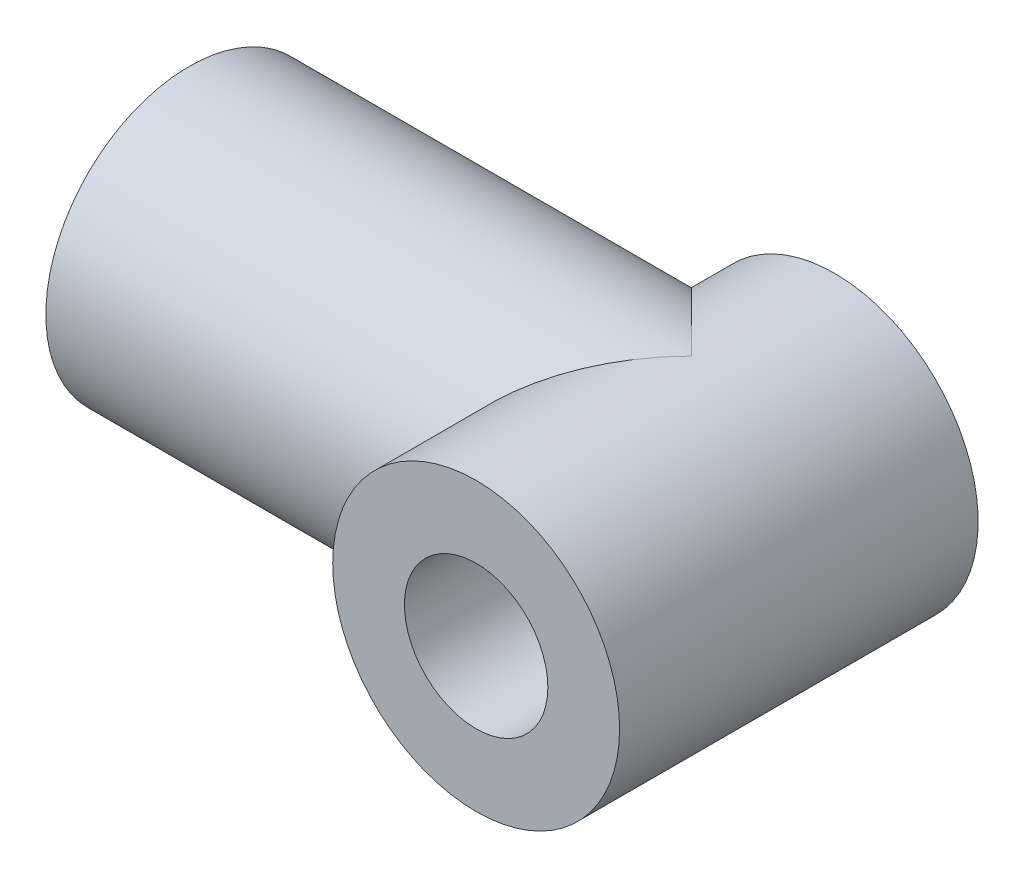
from build123d import *

# Parameters (mm, degrees)
SKETCH1_R           = 6
SKETCH1_R_2         = 3
BOSS_EXTRUDE1_DEPTH = 15
SKETCH2_R           = 6
SKETCH2_R_2         = 3
BOSS_EXTRUDE2_DEPTH = 21
SKETCH3_R           = 3
CUT_EXTRUDE1_DEPTH  = 16.0000001


with BuildPart() as part:
    # Sketch1 → Boss-Extrude1 (new body)
    with BuildSketch(Plane.XY):
        Circle(SKETCH1_R)
        Circle(SKETCH1_R_2, mode=Mode.SUBTRACT)
    extrude(amount=BOSS_EXTRUDE1_DEPTH)

    # Sketch2 → Boss-Extrude2 (add)
    with BuildSketch(Plane(origin=(0, 0, 0), x_dir=(0, 0, -1), z_dir=(1, 0, 0))):
        with Locations((-6, 0)):
            Circle(SKETCH2_R)
        with Locations((-6, 0)):
            Circle(SKETCH2_R_2, mode=Mode.SUBTRACT)
    extrude(amount=-BOSS_EXTRUDE2_DEPTH)

    # Sketch3 → Cut-Extrude1 (cut, through all)
    with BuildSketch(Plane(origin=(0, 0, 0), x_dir=(-1, 0, 0), z_dir=(0, 0, -1))):
        Circle(SKETCH3_R)
    extrude(amount=-CUT_EXTRUDE1_DEPTH, mode=Mode.SUBTRACT)


solid = part.part
